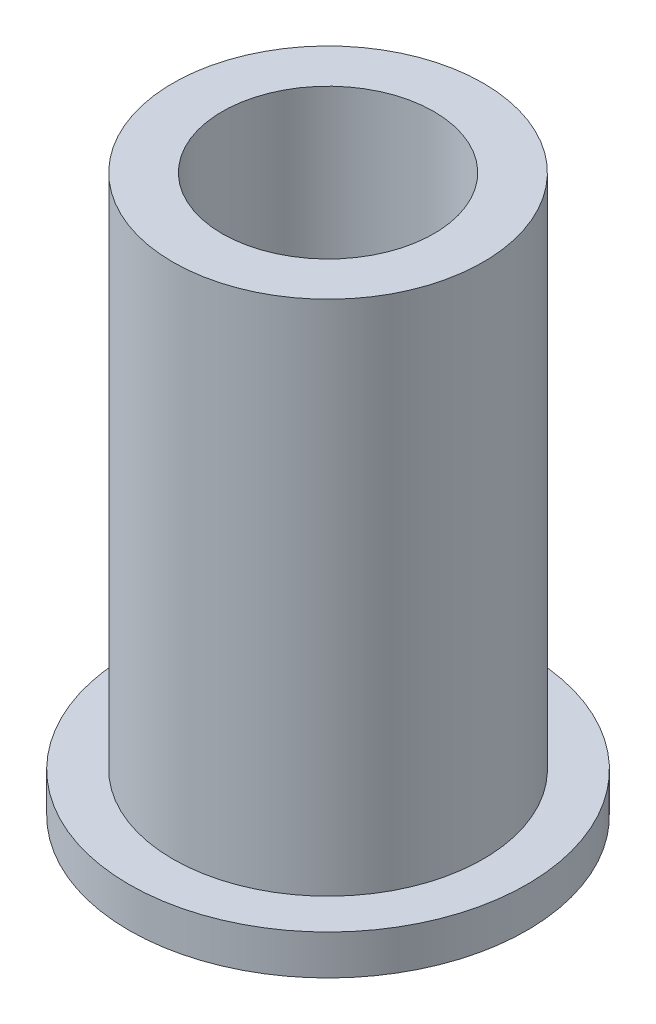
from build123d import *

# Parameters (mm, degrees)
SKETCH1_R               = 6.35
BOSS_EXTRUDE1_DEPTH     = 1.27
SKETCH2_R               = 4.95
SKETCH2_R_2             = 3.3782
BOSS_EXTRUDE2_DEPTH     = 16.49959986
SKETCH3_R               = 3.3782
CUT_EXTRUDE1_DEPTH      = 1
CUT_EXTRUDE1_DEPTH_BACK = 18.76959986


with BuildPart() as part:
    # Sketch1 → Boss-Extrude1 (new body)
    with BuildSketch(Plane(origin=(0, 0, 0), x_dir=(1, 0, 0), z_dir=(0, 1, 0))):
        Circle(SKETCH1_R)
    extrude(amount=BOSS_EXTRUDE1_DEPTH)

    # Sketch2 → Boss-Extrude2 (add)
    with BuildSketch(Plane(origin=(0, 1.27, 0), x_dir=(1, 0, 0), z_dir=(0, 1, 0))):
        Circle(SKETCH2_R)
        Circle(SKETCH2_R_2, mode=Mode.SUBTRACT)
    extrude(amount=BOSS_EXTRUDE2_DEPTH)

    # Sketch3 → Cut-Extrude1 (cut, two sides)
    with BuildSketch(Plane(origin=(0, 0, 0), x_dir=(-1, 0, 0), z_dir=(0, -1, 0))) as cut_extrude1_sk:
        Circle(SKETCH3_R)
    extrude(amount=CUT_EXTRUDE1_DEPTH, mode=Mode.SUBTRACT)
    extrude(cut_extrude1_sk.sketch, amount=-CUT_EXTRUDE1_DEPTH_BACK, mode=Mode.SUBTRACT)


solid = part.part
